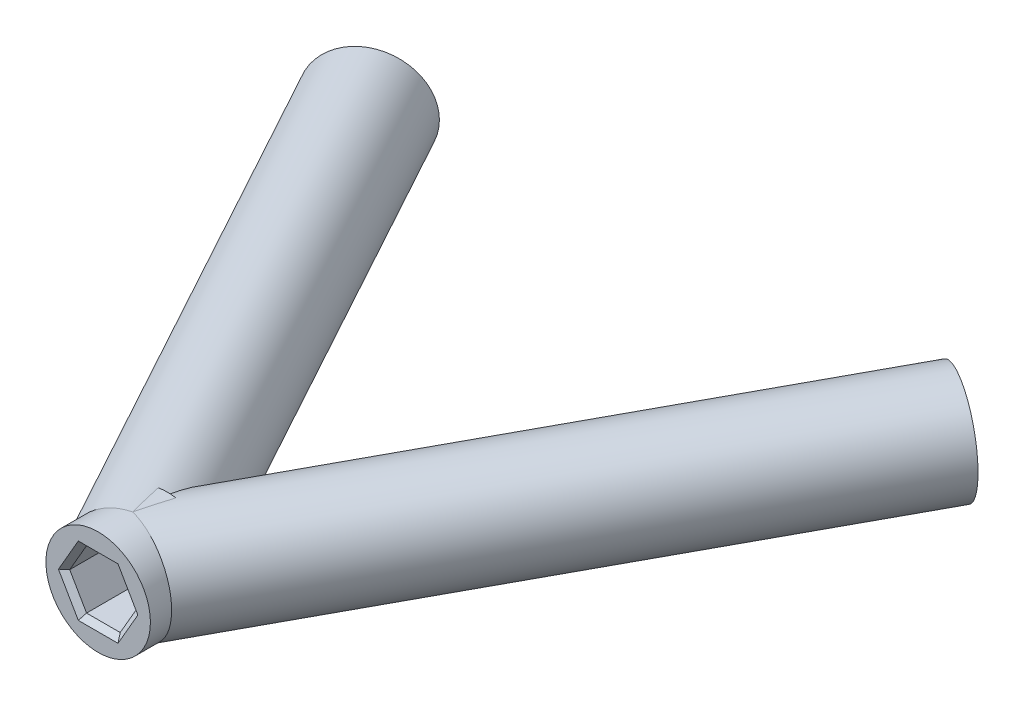
from build123d import *

# Parameters (mm, degrees)
SKETCH1_W           = 5
SKETCH1_H           = 6.6
BOSS_EXTRUDE1_REACH = 64.005
SKETCH21_R          = 5
BOSS_EXTRUDE2_REACH = 78.152
SKETCH22_R          = 5
CUT_EXTRUDE3_DEPTH  = 6.6
CUT_EXTRUDE4_DEPTH  = 6.6
CUT_EXTRUDE5_DEPTH  = 6.6
CHAMFER2_SIZE       = 0.5


with BuildPart() as part:
    # Sketch1 → Revolve-Thin1 (revolve)
    with BuildSketch(Plane(origin=(0, 0, 0), x_dir=(1, 0, 0), z_dir=(0, 1, 0))):
        with Locations((-2.5, 20.8)):
            Rectangle(SKETCH1_W, SKETCH1_H)
    revolve(axis=Axis((0, 0, -17.5), (0, 0, -1)))

    # Sketch21 → Boss-Extrude1 (add, up to next)
    with BuildSketch(Plane(origin=(-35.950232756, 0, -65.780747057), x_dir=(0.877503712, 0, -0.479569845), z_dir=(0.479569845, 0, 0.877503712)), mode=Mode.PRIVATE) as boss_extrude1_sk1:
        with Locations((9.975052777, 0)):
            Circle(SKETCH21_R)
    boss_extrude1_tool1 = extrude(boss_extrude1_sk1.sketch, amount=BOSS_EXTRUDE1_REACH, mode=Mode.PRIVATE) - part.part
    add(boss_extrude1_tool1.solids().sort_by_distance((-27.197087, 0, -70.564482))[0])

    # Sketch22 → Boss-Extrude2 (add, up to next)
    with BuildSketch(Plane(origin=(36.517428466, 0, -67.14845845), x_dir=(0.878494382, 0, 0.477752677), z_dir=(-0.477752677, 0, 0.878494382)), mode=Mode.PRIVATE) as boss_extrude2_sk1:
        with Locations((-9.937255677, 0)):
            Circle(SKETCH22_R)
    boss_extrude2_tool1 = extrude(boss_extrude2_sk1.sketch, amount=BOSS_EXTRUDE2_REACH, mode=Mode.PRIVATE) - part.part
    add(boss_extrude2_tool1.solids().sort_by_distance((27.787605, 0, -71.896009))[0])

    # Sketch29 → Cut-Extrude3 (cut)
    with BuildSketch(Plane(origin=(-35.950232756, 0, -65.780747057), x_dir=(-0.877503712, 0, 0.479569845), z_dir=(-0.479569845, 0, -0.877503712))):
        Polygon((-7.089955208, 1.433531311), (-9.773978525, 3.215333442), (-12.659076094, 1.781802131), (-12.860150346, -1.433531311), (-10.176127029, -3.215333442), (-7.29102946, -1.781802131), align=None)
    extrude(amount=-CUT_EXTRUDE3_DEPTH, mode=Mode.SUBTRACT)

    # Sketch30 → Cut-Extrude4 (cut)
    with BuildSketch(Plane(origin=(36.517428466, 0, -67.14845845), x_dir=(-0.878494382, 0, -0.477752677), z_dir=(0.477752677, 0, -0.878494382))):
        Polygon((12.621278993, 1.781802131), (9.736181425, 3.215333442), (7.052158108, 1.433531311), (7.25323236, -1.781802131), (10.138329929, -3.215333442), (12.822353245, -1.433531311), align=None)
    extrude(amount=-CUT_EXTRUDE4_DEPTH, mode=Mode.SUBTRACT)

    # Sketch18 → Cut-Extrude5 (cut)
    with BuildSketch(Plane.XY.offset(-17.5)):
        Polygon((1.610807251, 2.79), (-1.610807251, 2.79), (-3.221614502, 0), (-1.610807251, -2.79), (1.610807251, -2.79), (3.221614502, 0), align=None)
    extrude(amount=-CUT_EXTRUDE5_DEPTH, mode=Mode.SUBTRACT)

    # Chamfer2
    chamfer2_edges = [part.edges().sort_by_distance(p)[0] for p in [
        (-29.640549045, -0.17413541, -69.229090352),
        (-28.551150535, 2.324432377, -69.824464101),
        (-26.107688412, 2.498567787, -71.159855321),
        (-24.753624798, 0.17413541, -71.899872792),
        (-25.843023308, -2.324432377, -71.304499043),
        (-28.286485432, -2.498567787, -69.969107823),
        (25.341384472, 0.17413541, -73.226340155),
        (26.696976775, 2.498567787, -72.489126731),
        (29.143197481, 2.324432377, -71.158795526),
        (30.233825884, -0.17413541, -70.565677745),
        (28.87823358, -2.498567787, -71.302891169),
        (26.432012874, -2.324432377, -72.633222374),
        (2.416210877, 1.395, -17.5),
        (0, 2.79, -17.5),
        (-2.416210877, 1.395, -17.5),
        (-2.416210877, -1.395, -17.5),
        (0, -2.79, -17.5),
        (2.416210877, -1.395, -17.5),
    ]]
    chamfer(chamfer2_edges, length=CHAMFER2_SIZE)


solid = part.part
